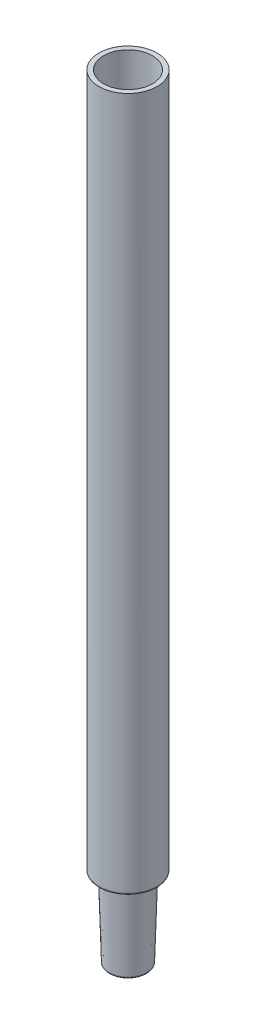
from build123d import *

# Parameters (mm, degrees)
VERRUNDUNG1_R = 0.2


with BuildPart() as part:
    # Skizze1 → Rotation1 (revolve)
    with BuildSketch(Plane.XY):
        Polygon((-2.6, 82.5), (-3.1, 82.5), (-3.1, 8.5), (-2.25, 8.5), (-2, 0), (-1.5, 0), (-1.764705882, 9), (-2.6, 9), align=None)
    revolve(axis=Axis((0, 0, 0), (0, -1, 0)))

    # Verrundung1
    verrundung1_edges = [part.edges().sort_by_distance(p)[0] for p in [
        (1.5, 0, 0),
        (2, 0, 0),
        (2.25, 8.5, 0),
        (3.1, 8.5, 0),
    ]]
    fillet(verrundung1_edges, radius=VERRUNDUNG1_R)


solid = part.part
